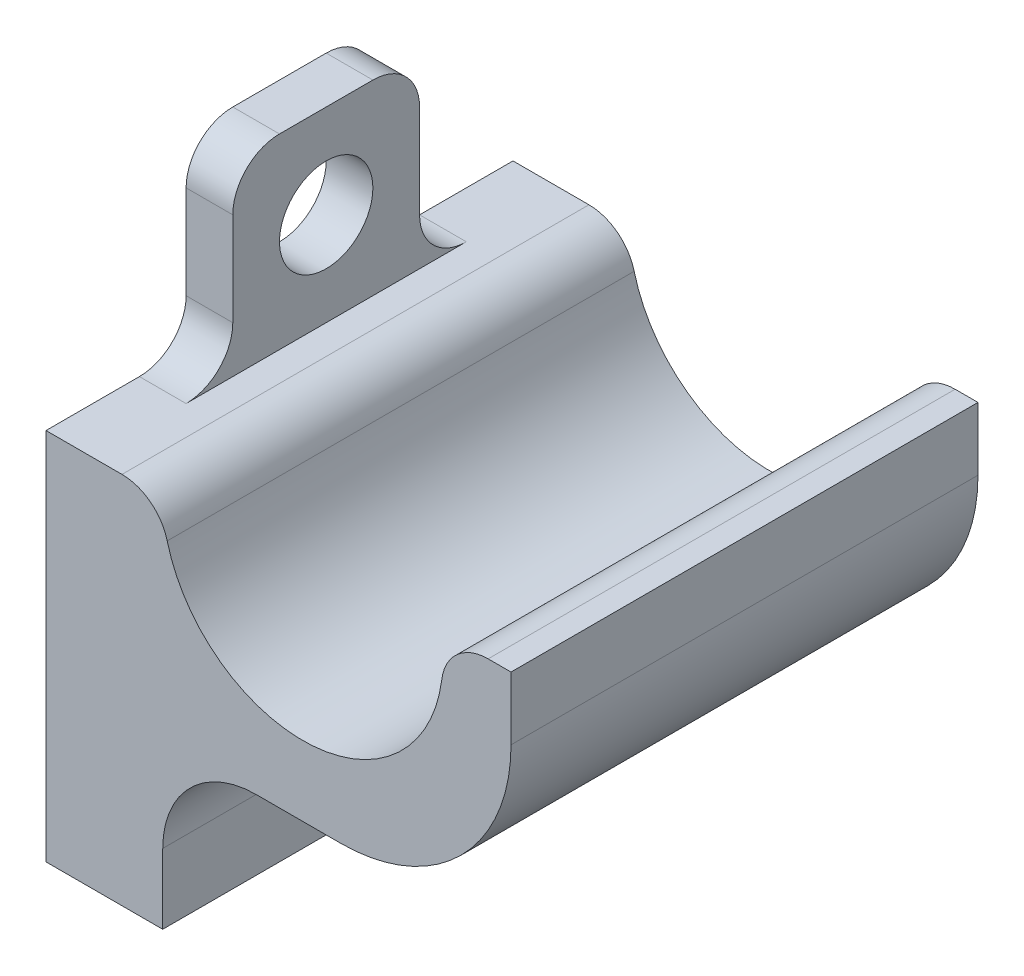
from build123d import *

# Parameters (mm, degrees)
SALIENTE_EXTRUIR1_DEPTH      = 10
SALIENTE_EXTRUIR1_DEPTH_BACK = 10
SALIENTE_EXTRUIR2_DEPTH      = 2
SALIENTE_EXTRUIR2_DEPTH_BACK = 2
REDONDEO1_R                  = 4
REDONDEO4_R                  = 7.3
REDONDEO2_R                  = 2
CROQUIS4_W                   = 2
CROQUIS4_H                   = 8
SALIENTE_EXTRUIR3_DEPTH      = 8
REDONDEO3_R                  = 2
CORTAR_EXTRUIR1_REACH        = 36.964
CROQUIS5_R                   = 2


with BuildPart() as part:
    # Croquis2 → Saliente-Extruir1 (new, two sides: drawn at the far end of the back side and taken through both)
    with BuildSketch(Plane.XY.offset(-SALIENTE_EXTRUIR1_DEPTH_BACK)):
        with BuildLine():
            Line((23.96097083, 4.310370238), (23.96097083, 20.310370238))
            Line((23.96097083, 20.310370238), (28.96097083, 20.310370238))
            ThreePointArc((28.96097083, 20.310370238), (35.462728392, 14.331387102), (40.877050613, 21.310370238))
            Line((40.877050613, 21.310370238), (43.877050613, 21.310370238))
            Line((43.877050613, 21.310370238), (43.877050613, 11.310370238))
            Line((43.877050613, 11.310370238), (28.96097083, 11.310370238))
            Line((28.96097083, 11.310370238), (28.96097083, 4.310370238))
            Line((28.96097083, 4.310370238), (23.96097083, 4.310370238))
        make_face()
    extrude(amount=SALIENTE_EXTRUIR1_DEPTH + SALIENTE_EXTRUIR1_DEPTH_BACK)

    # Croquis3 → Saliente-Extruir2 (add, two sides: drawn at the far end of the back side and taken through both)
    with BuildSketch(Plane.XY.offset(-SALIENTE_EXTRUIR2_DEPTH_BACK)):
        Polygon((28.96097083, 4.310370238), (28.96097083, 11.310370238), (36.419010722, 11.310370238), align=None)
    extrude(amount=SALIENTE_EXTRUIR2_DEPTH + SALIENTE_EXTRUIR2_DEPTH_BACK)

    # Redondeo1
    redondeo1_edges = [part.edges().sort_by_distance(p)[0] for p in [
        (28.96097083, 11.310370238, -6),
        (28.96097083, 11.310370238, 6),
    ]]
    fillet(redondeo1_edges, radius=REDONDEO1_R)

    # Redondeo4
    redondeo4_edges = [part.edges().sort_by_distance(p)[0] for p in [
        (43.877050613, 11.310370238, 0),
    ]]
    fillet(redondeo4_edges, radius=REDONDEO4_R)

    # Redondeo2
    redondeo2_edges = [part.edges().sort_by_distance(p)[0] for p in [
        (28.96097083, 20.310370238, 0),
        (40.877050613, 21.310370238, 0),
    ]]
    fillet(redondeo2_edges, radius=REDONDEO2_R)

    # Croquis4 → Saliente-Extruir3 (add)
    with BuildSketch(Plane(origin=(0, 20.310370238, 0), x_dir=(1, 0, 0), z_dir=(0, 1, 0))):
        with Locations((24.96097083, 0)):
            Rectangle(CROQUIS4_W, CROQUIS4_H)
    extrude(amount=SALIENTE_EXTRUIR3_DEPTH)

    # Redondeo3
    redondeo3_edges = [part.edges().sort_by_distance(p)[0] for p in [
        (24.96097083, 28.310370238, 4),
        (24.96097083, 28.310370238, -4),
        (24.96097083, 20.310370238, -4),
        (24.96097083, 20.310370238, 4),
    ]]
    fillet(redondeo3_edges, radius=REDONDEO3_R)

    # Croquis5 → Cortar-Extruir1 (cut, up to next)
    with BuildSketch(Plane(origin=(25.96097083, 0, 0), x_dir=(0, 0, -1), z_dir=(1, 0, 0)), mode=Mode.PRIVATE) as cortar_extruir1_sk1:
        with Locations((0, 24.310370238)):
            Circle(CROQUIS5_R)
    cortar_extruir1_tool1 = extrude(cortar_extruir1_sk1.sketch, amount=-CORTAR_EXTRUIR1_REACH, mode=Mode.PRIVATE) & part.part
    add(cortar_extruir1_tool1.solids().sort_by_distance((25.960971, 24.31037, 0))[0], mode=Mode.SUBTRACT)


solid = part.part
